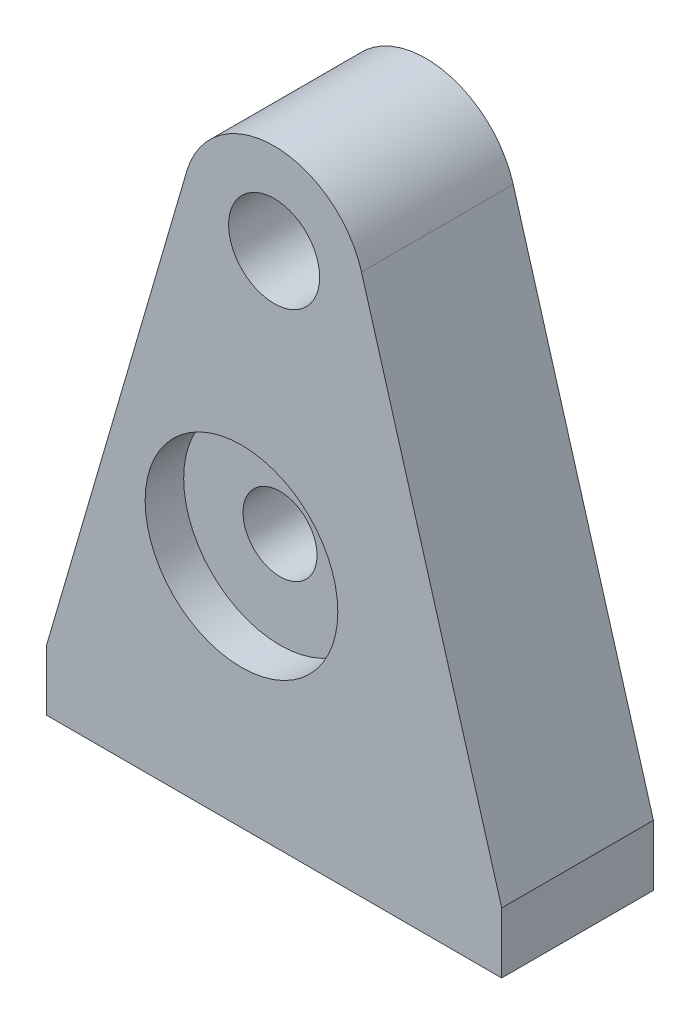
from build123d import *

# Parameters (mm, degrees)
SKETCH1_R                                  = 1.5
BOSS_EXTRUDE1_DEPTH                        = 5
CBORE_FOR_2_HEX_MACHINE_SCREW1_D           = 2.4384
CBORE_FOR_2_HEX_MACHINE_SCREW1_CBORE_D     = 6.35
CBORE_FOR_2_HEX_MACHINE_SCREW1_CBORE_DEPTH = 1.27


with BuildPart() as part:
    # Sketch1 → Boss-Extrude1 (new body)
    with BuildSketch(Plane.XY):
        with BuildLine():
            Line((15, 0), (10.38, 15.84))
            ThreePointArc((10.38, 15.84), (7.5, 18), (4.62, 15.84))
            Line((4.62, 15.84), (0, 0))
            Line((0, 0), (0, -2))
            Line((0, -2), (15, -2))
            Line((15, -2), (15, 0))
        make_face()
        with Locations((7.5, 15)):
            Circle(SKETCH1_R, mode=Mode.SUBTRACT)
    extrude(amount=BOSS_EXTRUDE1_DEPTH)

    # CBORE for #2 Hex Machine Screw1 (through all)
    with Locations(Plane.XY.offset(5)):
        with Locations((6.423403237, 5.750188816)):
            CounterBoreHole(CBORE_FOR_2_HEX_MACHINE_SCREW1_D / 2, CBORE_FOR_2_HEX_MACHINE_SCREW1_CBORE_D / 2, CBORE_FOR_2_HEX_MACHINE_SCREW1_CBORE_DEPTH)


solid = part.part
